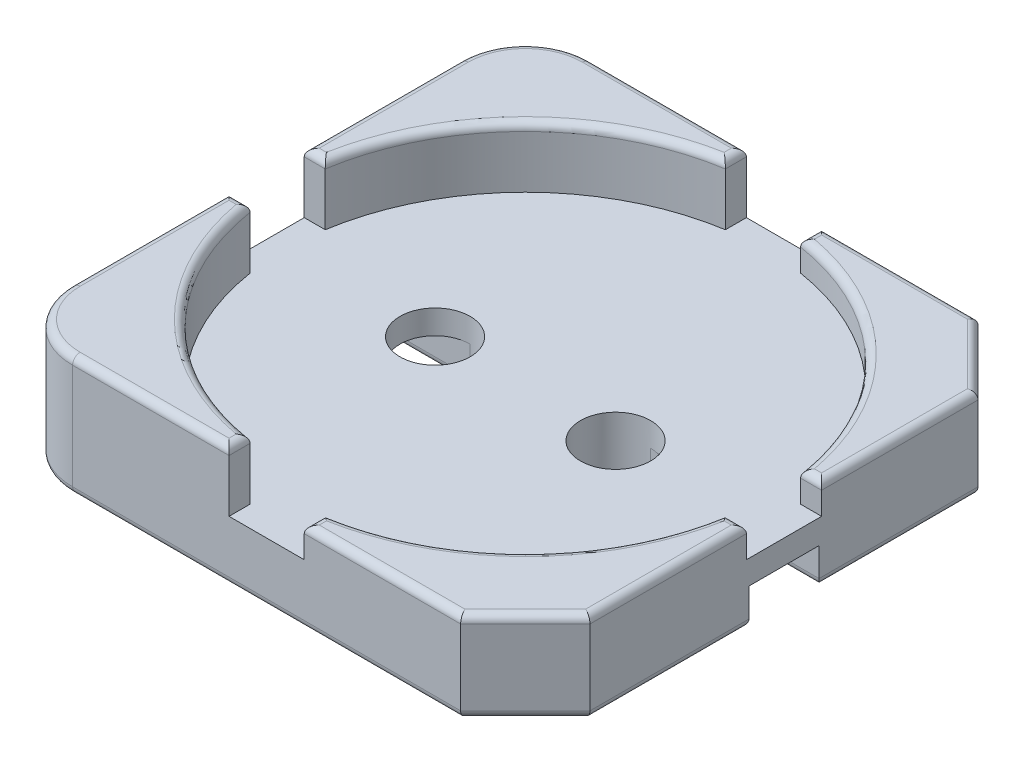
from build123d import *

# Parameters (mm, degrees)
SALIENTE_EXTRUIR1_DEPTH = 1
CORTAR_EXTRUIR1_DEPTH   = 0.5
CROQUIS4_W              = 2.15
CROQUIS4_H              = 4.3
CORTAR_EXTRUIR2_DEPTH   = 0.25
CORTAR_EXTRUIR3_DEPTH   = 0.3
CROQUIS6_R              = 0.291547595
CORTAR_EXTRUIR4_DEPTH   = 4.081395788
REDONDEO1_R             = 0.0625


with BuildPart() as part:
    # Croquis2 → Saliente-Extruir1 (new body)
    with BuildSketch(Plane(origin=(0, 0, 0), x_dir=(1, 0, 0), z_dir=(0, 1, 0))):
        with BuildLine():
            Line((1.6125, 2.15), (2.15, 1.6125))
            Line((2.15, 1.6125), (2.15, -1.6125))
            Line((2.15, -1.6125), (1.6125, -2.15))
            Line((1.6125, -2.15), (-1.6125, -2.15))
            ThreePointArc((-1.6125, -2.15), (-1.992569895, -1.992569895), (-2.15, -1.6125))
            Line((-2.15, -1.6125), (-2.15, 1.6125))
            ThreePointArc((-2.15, 1.6125), (-1.992569895, 1.992569895), (-1.6125, 2.15))
            Line((-1.6125, 2.15), (1.6125, 2.15))
        make_face()
    extrude(amount=SALIENTE_EXTRUIR1_DEPTH)

    # Croquis3 → Cortar-Extruir1 (cut)
    with BuildSketch(Plane(origin=(0, 1, 0), x_dir=(1, 0, 0), z_dir=(0, 1, 0))):
        with BuildLine():
            ThreePointArc((-0.3125, 1.975435079), (-1.414213562, 1.414213562), (-1.975435079, 0.3125))
            Line((-1.975435079, 0.3125), (-2.15, 0.3125))
            Line((-2.15, 0.3125), (-2.15, -0.3125))
            Line((-2.15, -0.3125), (-1.975435079, -0.3125))
            ThreePointArc((-1.975435079, -0.3125), (-1.414213562, -1.414213562), (-0.3125, -1.975435079))
            Line((-0.3125, -1.975435079), (-0.3125, -2.15))
            Line((-0.3125, -2.15), (0.3125, -2.15))
            Line((0.3125, -2.15), (0.3125, -1.975435079))
            ThreePointArc((0.3125, -1.975435079), (1.414213562, -1.414213562), (1.975435079, -0.3125))
            Line((1.975435079, -0.3125), (2.15, -0.3125))
            Line((2.15, -0.3125), (2.15, 0.3125))
            Line((2.15, 0.3125), (1.975435079, 0.3125))
            ThreePointArc((1.975435079, 0.3125), (1.414213562, 1.414213562), (0.3125, 1.975435079))
            Line((0.3125, 1.975435079), (0.3125, 2.15))
            Line((0.3125, 2.15), (-0.3125, 2.15))
            Line((-0.3125, 2.15), (-0.3125, 1.975435079))
        make_face()
    extrude(amount=-CORTAR_EXTRUIR1_DEPTH, mode=Mode.SUBTRACT)

    # Croquis4 → Cortar-Extruir2 (cut)
    with BuildSketch(Plane(origin=(0, 1, 0), x_dir=(1, 0, 0), z_dir=(0, 1, 0))):
        with Locations((1.075, 0)):
            Rectangle(CROQUIS4_W, CROQUIS4_H)
    extrude(amount=-CORTAR_EXTRUIR2_DEPTH, mode=Mode.SUBTRACT)

    # Croquis5 → Cortar-Extruir3 (cut)
    with BuildSketch(Plane(origin=(0, 0, 0), x_dir=(-1, 0, 0), z_dir=(0, -1, 0))):
        with BuildLine():
            Line((2.15, -0.291547595), (0.75, -0.291547595))
            ThreePointArc((0.75, -0.291547595), (0.458452405, 0), (0.75, 0.291547595))
            Line((0.75, 0.291547595), (2.15, 0.291547595))
            Line((2.15, 0.291547595), (2.15, -0.291547595))
        make_face()
        with BuildLine():
            Line((-2.15, -0.291547595), (-2.15, 0.291547595))
            Line((-2.15, 0.291547595), (-0.75, 0.291547595))
            ThreePointArc((-0.75, 0.291547595), (-0.458452405, 0), (-0.75, -0.291547595))
            Line((-0.75, -0.291547595), (-2.15, -0.291547595))
        make_face()
    extrude(amount=-CORTAR_EXTRUIR3_DEPTH, mode=Mode.SUBTRACT)

    # Croquis6 → Cortar-Extruir4 (cut, through all)
    with BuildSketch(Plane(origin=(0, 0.5, 0), x_dir=(1, 0, 0), z_dir=(0, 1, 0))):
        with Locations(Location((0.75, 0, 0), (0, 0, 270))):
            Circle(CROQUIS6_R)
        with Locations(Location((-0.75, 0, 0), (0, 0, 90))):
            Circle(CROQUIS6_R)
    extrude(amount=-CORTAR_EXTRUIR4_DEPTH, mode=Mode.SUBTRACT)

    # Redondeo1
    redondeo1_edges = [part.edges().sort_by_distance(p)[0] for p in [
        (-2.15, 1, -0.9625),
        (-1.992569895, 0, -1.992569895),
        (0, 0, -2.15),
        (2.15, 0, -0.952023797),
        (-2.15, 0, 0.952023797),
        (-1.45, 0, -0.291547595),
        (-0.458452405, 0, 0),
        (-1.45, 0, 0.291547595),
        (-1.992569895, 1, 1.992569895),
        (1.45, 0, 0.291547595),
        (0.458452405, 0, 0),
        (1.45, 0, -0.291547595),
        (-0.9625, 1, 2.15),
        (-0.9625, 1, -2.15),
        (-2.15, 1, 0.9625),
        (-0.3125, 1, -2.062717539),
        (-2.062717539, 1, 0.3125),
        (-1.414213562, 1, -1.414213562),
        (-2.062717539, 1, -0.3125),
        (-1.414213562, 1, 1.414213562),
        (-0.3125, 1, 2.062717539),
        (-1.992569895, 1, -1.992569895),
        (0.3125, 0.75, 2.062717539),
        (1.88125, 0, -1.88125),
        (2.15, 0, 0.952023797),
        (1.88125, 0, 1.88125),
        (0.9625, 0.75, -2.15),
        (2.15, 0.75, 0.9625),
        (2.15, 0.75, -0.9625),
        (0.9625, 0.75, 2.15),
        (1.88125, 0.75, 1.88125),
        (1.414213562, 0.75, 1.414213562),
        (2.062717539, 0.75, 0.3125),
        (1.88125, 0.75, -1.88125),
        (1.414213562, 0.75, -1.414213562),
        (0.3125, 0.75, -2.062717539),
        (0, 0, 2.15),
        (-1.992569895, 0, 1.992569895),
        (2.062717539, 0.75, -0.3125),
        (-2.15, 0, -0.952023797),
    ]]
    fillet(redondeo1_edges, radius=REDONDEO1_R)


solid = part.part
